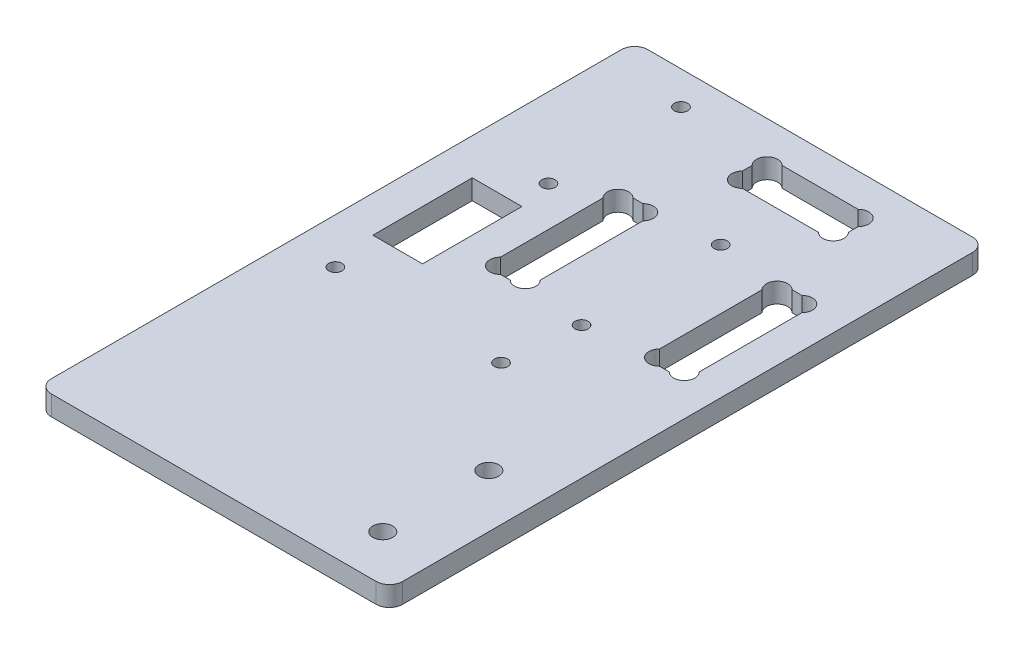
from build123d import *

# Parameters (mm, degrees)
EXTRUSION1_DEPTH        = 3
ESQUISSE2_R             = 1.5
ENL_V_MAT_EXTRU_1_DEPTH = 4
ESQUISSE4_R             = 1
ESQUISSE4_W             = 7.5
ESQUISSE4_H             = 15
ENL_V_MAT_EXTRU_2_DEPTH = 4
ESQUISSE5_R             = 1
ENL_V_MAT_EXTRU_3_DEPTH = 4


with BuildPart() as part:
    # Esquisse1 → Extrusion1 (new body)
    with BuildSketch(Plane(origin=(0, 0, 0), x_dir=(1, 0, 0), z_dir=(0, 1, 0))):
        with BuildLine():
            Line((0, 88), (0, 2))
            ThreePointArc((0, 2), (0.585786438, 0.585786438), (2, 0))
            Line((2, 0), (51, 0))
            ThreePointArc((51, 0), (52.414213562, 0.585786438), (53, 2))
            Line((53, 2), (53, 88))
            ThreePointArc((53, 88), (52.414213562, 89.414213562), (51, 90))
            Line((51, 90), (2, 90))
            ThreePointArc((2, 90), (0.585786438, 89.414213562), (0, 88))
        make_face()
    extrude(amount=EXTRUSION1_DEPTH)

    # Esquisse2 → Enlèv. mat.-Extru.1 (cut, through all)
    with BuildSketch(Plane.XZ):
        with Locations(Location((45, -23, 0), (0, 0, 270))):  # turned: the seam where the file's is
            Circle(ESQUISSE2_R)
        with Locations(Location((45, -7, 0), (0, 0, 270))):  # turned: the seam where the file's is
            Circle(ESQUISSE2_R)
        with BuildLine():
            Line((41, -82.7372583), (41, -81.2627417))
            ThreePointArc((41, -81.2627417), (41, -79), (38.7372583, -79))
            Line((38.7372583, -79), (27.2627417, -79))
            ThreePointArc((27.2627417, -79), (25, -79), (25, -81.2627417))
            Line((25, -81.2627417), (25, -82.7372583))
            ThreePointArc((25, -82.7372583), (25, -85), (27.2627417, -85))
            Line((27.2627417, -85), (38.7372583, -85))
            ThreePointArc((38.7372583, -85), (41, -85), (41, -82.7372583))
        make_face()
        with BuildLine():
            Line((45.7372583, -49.5), (44.2627417, -49.5))
            ThreePointArc((44.2627417, -49.5), (42, -49.5), (42, -51.7627417))
            Line((42, -51.7627417), (42, -67.2372583))
            ThreePointArc((42, -67.2372583), (42, -69.5), (44.2627417, -69.5))
            Line((44.2627417, -69.5), (45.7372583, -69.5))
            ThreePointArc((45.7372583, -69.5), (48, -69.5), (48, -67.2372583))
            Line((48, -67.2372583), (48, -51.7627417))
            ThreePointArc((48, -51.7627417), (48, -49.5), (45.7372583, -49.5))
        make_face()
        with BuildLine():
            Line((24, -67.2372583), (24, -51.7627417))
            ThreePointArc((24, -51.7627417), (24, -49.5), (21.7372583, -49.5))
            Line((21.7372583, -49.5), (20.2627417, -49.5))
            ThreePointArc((20.2627417, -49.5), (18, -49.5), (18, -51.7627417))
            Line((18, -51.7627417), (18, -67.2372583))
            ThreePointArc((18, -67.2372583), (18, -69.5), (20.2627417, -69.5))
            Line((20.2627417, -69.5), (21.7372583, -69.5))
            ThreePointArc((21.7372583, -69.5), (24, -69.5), (24, -67.2372583))
        make_face()
    extrude(amount=-ENL_V_MAT_EXTRU_1_DEPTH, mode=Mode.SUBTRACT)

    # Esquisse4 → Enlèv. mat.-Extru.2 (cut, through all)
    with BuildSketch(Plane(origin=(0, 3, 0), x_dir=(1, 0, 0), z_dir=(0, 1, 0))):
        with Locations(Location((12, 85, 0), (0, 0, 270))):  # turned: the seam where the file's is
            Circle(ESQUISSE4_R)
        with Locations(Location((12, 65, 0), (0, 0, 270))):  # turned: the seam where the file's is
            Circle(ESQUISSE4_R)
        with Locations(Location((33, 70, 0), (0, 0, 270))):  # turned: the seam where the file's is
            Circle(ESQUISSE4_R)
        with Locations(Location((33, 49, 0), (0, 0, 270))):  # turned: the seam where the file's is
            Circle(ESQUISSE4_R)
        with Locations((9.25, 52.5)):
            Rectangle(ESQUISSE4_W, ESQUISSE4_H)
    extrude(amount=-ENL_V_MAT_EXTRU_2_DEPTH, mode=Mode.SUBTRACT)

    # Esquisse5 → Enlèv. mat.-Extru.3 (cut, through all)
    with BuildSketch(Plane(origin=(0, 3, 0), x_dir=(1, 0, 0), z_dir=(0, 1, 0))):
        with Locations(Location((6.847371534, 38, 0), (0, 0, 270))):  # turned: the seam where the file's is
            Circle(ESQUISSE5_R)
        with Locations(Location((31.847371534, 38, 0), (0, 0, 270))):  # turned: the seam where the file's is
            Circle(ESQUISSE5_R)
    extrude(amount=-ENL_V_MAT_EXTRU_3_DEPTH, mode=Mode.SUBTRACT)


solid = part.part
